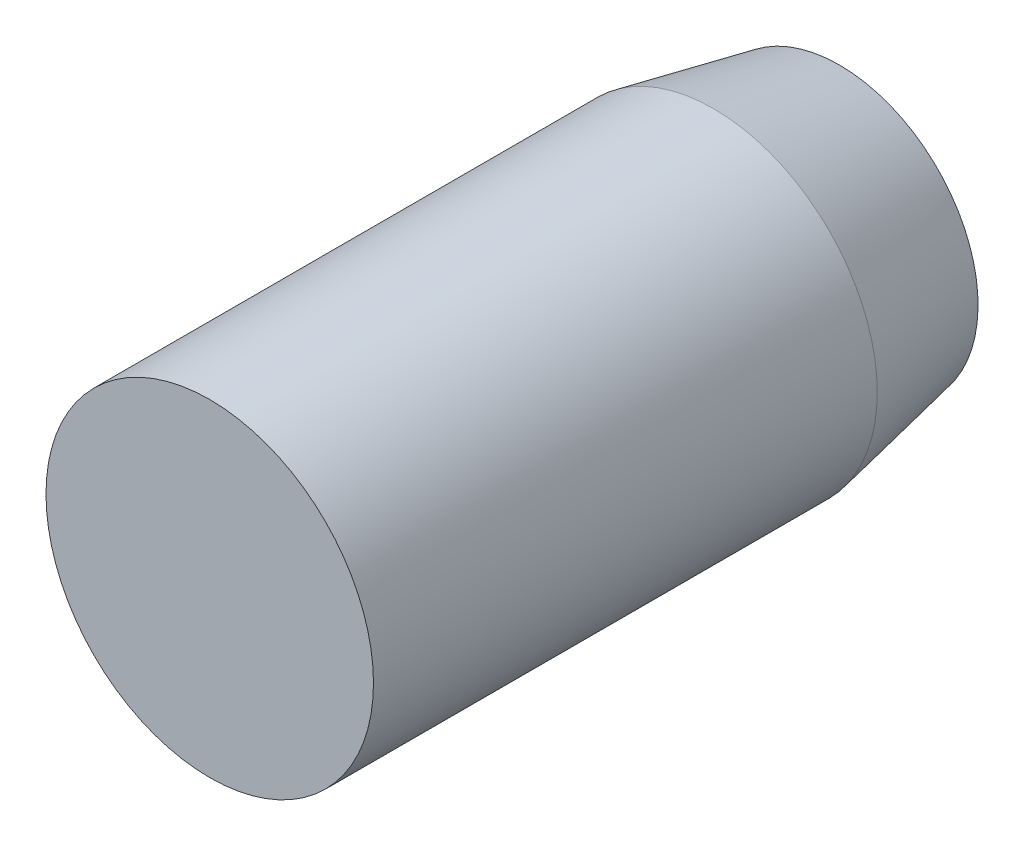
from build123d import *


with BuildPart() as part:
    # Sketch1 → Revolve1 (revolve)
    with BuildSketch(Plane(origin=(0, 0, 0), x_dir=(0, 0, -1), z_dir=(1, 0, 0))):
        Polygon((0, 0), (0, 6.5), (20, 6.5), (25, 5.5), (25, 0), align=None)
    revolve(axis=Axis((0, 0, -25), (0, 0, 1)))


solid = part.part
